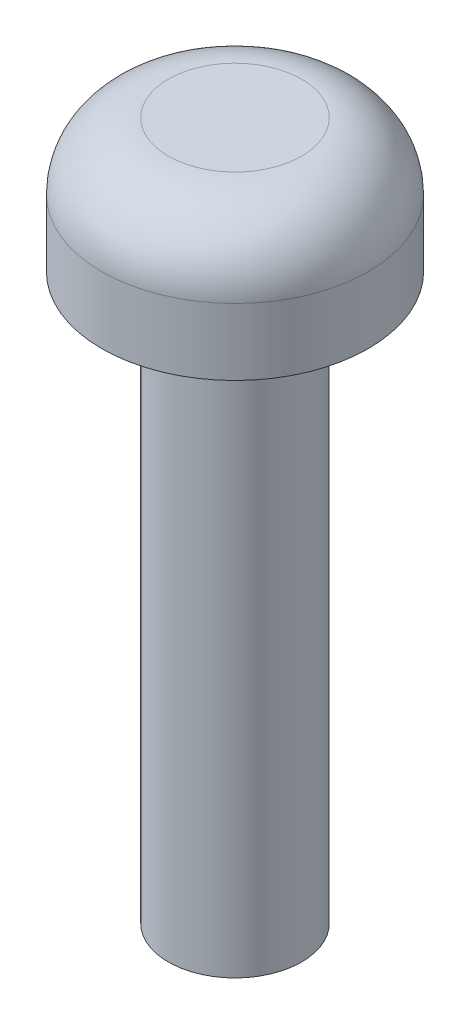
from build123d import *

# Parameters (mm, degrees)
SKETCH1_R           = 3
BOSS_EXTRUDE1_DEPTH = 3
FILLET1_R           = 1.5
SKETCH2_R           = 1.5
BOSS_EXTRUDE2_DEPTH = 12.7


with BuildPart() as part:
    # Sketch1 → Boss-Extrude1 (new body)
    with BuildSketch(Plane(origin=(0, 0, 0), x_dir=(1, 0, 0), z_dir=(0, 1, 0))):
        Circle(SKETCH1_R)
    extrude(amount=BOSS_EXTRUDE1_DEPTH)

    # Fillet1
    fillet1_edges = [part.edges().sort_by_distance(p)[0] for p in [
        (-3, 3, 0),
    ]]
    fillet(fillet1_edges, radius=FILLET1_R)

    # Sketch2 → Boss-Extrude2 (add)
    with BuildSketch(Plane.XZ):
        Circle(SKETCH2_R)
    extrude(amount=BOSS_EXTRUDE2_DEPTH)


solid = part.part
